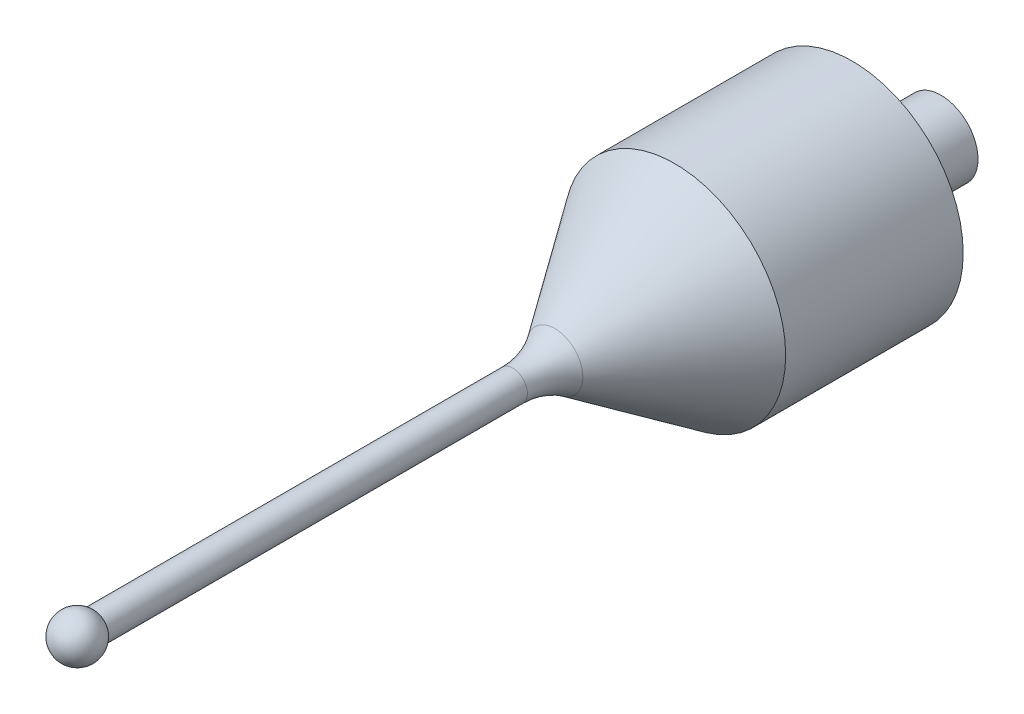
from build123d import *

# Parameters (mm, degrees)
SKETCH2_R           = 1
BOSS_EXTRUDE1_DEPTH = 30
FILLET1_R           = 5


with BuildPart() as part:
    # Sketch1 → Revolve1 (revolve)
    with BuildSketch(Plane(origin=(0, 0, 0), x_dir=(1, 0, 0), z_dir=(0, 1, 0))):
        Polygon((0, 0), (0, 11.925), (2.5, 11.925), (2.5, 5.925), (7.5, 5.925), (7.5, -6.075), (1, -15.460714286), (0, -15.460714286), align=None)
    revolve(axis=Axis((0, 0, 0), (0, 0, -1)))

    # Sketch2 → Boss-Extrude1 (add)
    with BuildSketch(Plane.XY.offset(15.460714286)):
        Circle(SKETCH2_R)
    extrude(amount=BOSS_EXTRUDE1_DEPTH)

    # Fillet1
    fillet1_edges = [part.edges().sort_by_distance(p)[0] for p in [
        (-1, 0, 15.460714286),
    ]]
    fillet(fillet1_edges, radius=FILLET1_R)

    # Sketch4 → Revolve8 (revolve)
    with BuildSketch(Plane(origin=(0, 0, 46.460714286), x_dir=(-1, 0, 0), z_dir=(0, 0, -1))):
        with BuildLine():
            Line((-1.5, 0), (1.5, 0))
            ThreePointArc((1.5, 0), (0, -1.5), (-1.5, 0))
        make_face()
    revolve(axis=Axis((-1.5, 0, 46.460714286), (1, 0, 0)))


solid = part.part
